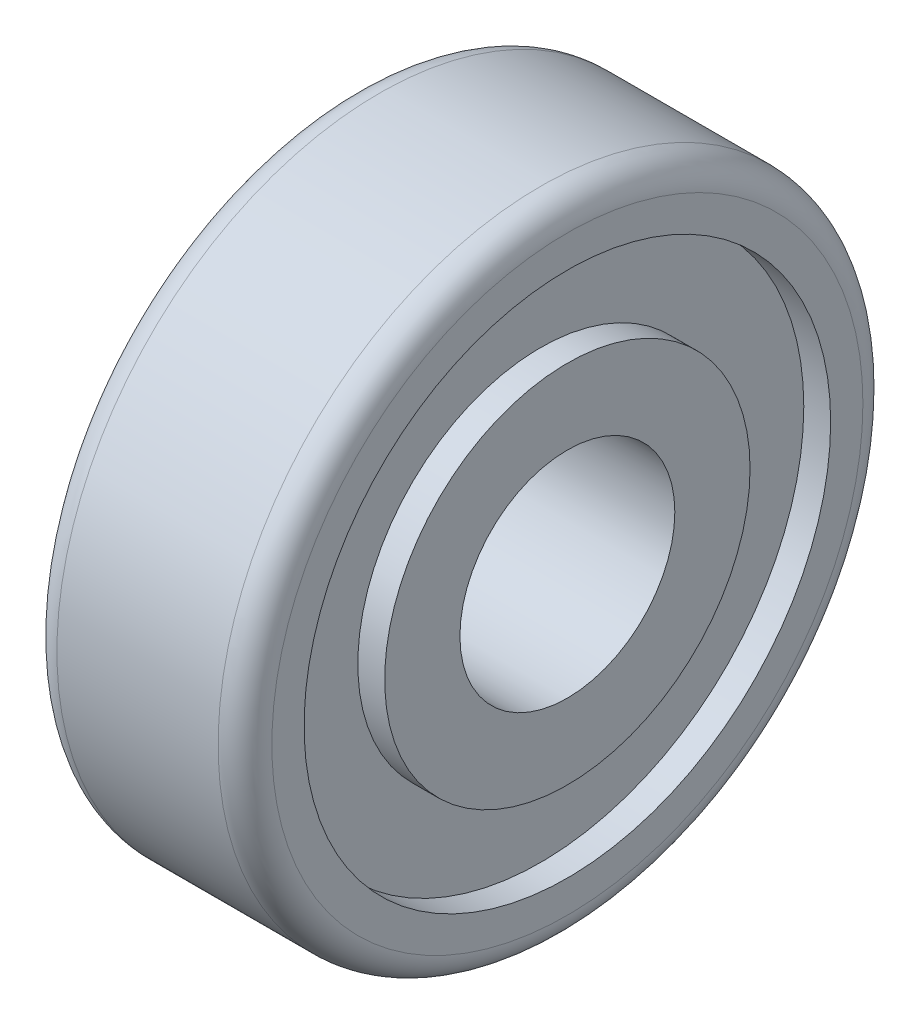
from build123d import *

# Parameters (mm, degrees)
SKETCH1_R           = 6
SKETCH1_R_2         = 2
BOSS_EXTRUDE1_DEPTH = 4
FILLET1_R           = 0.5
SKETCH2_R           = 4.9
SKETCH2_R_2         = 3.4
CUT_EXTRUDE1_DEPTH  = 0.5
SKETCH3_R           = 4.9
SKETCH3_R_2         = 3.4
CUT_EXTRUDE2_DEPTH  = 0.5


with BuildPart() as part:
    # Sketch1 → Boss-Extrude1 (new body)
    with BuildSketch(Plane(origin=(0, 0, 0), x_dir=(0, 0, -1), z_dir=(1, 0, 0))):
        Circle(SKETCH1_R)
        Circle(SKETCH1_R_2, mode=Mode.SUBTRACT)
    extrude(amount=BOSS_EXTRUDE1_DEPTH)

    # Fillet1
    fillet1_edges = [part.edges().sort_by_distance(p)[0] for p in [
        (0, 0, 6),
        (4, 0, 6),
    ]]
    fillet(fillet1_edges, radius=FILLET1_R)

    # Sketch2 → Cut-Extrude1 (cut)
    with BuildSketch(Plane(origin=(4, 0, 0), x_dir=(0, 0, -1), z_dir=(1, 0, 0))):
        Circle(SKETCH2_R)
        Circle(SKETCH2_R_2, mode=Mode.SUBTRACT)
    extrude(amount=-CUT_EXTRUDE1_DEPTH, mode=Mode.SUBTRACT)

    # Sketch3 → Cut-Extrude2 (cut)
    with BuildSketch(Plane.ZY):
        Circle(SKETCH3_R)
        Circle(SKETCH3_R_2, mode=Mode.SUBTRACT)
    extrude(amount=-CUT_EXTRUDE2_DEPTH, mode=Mode.SUBTRACT)


solid = part.part
